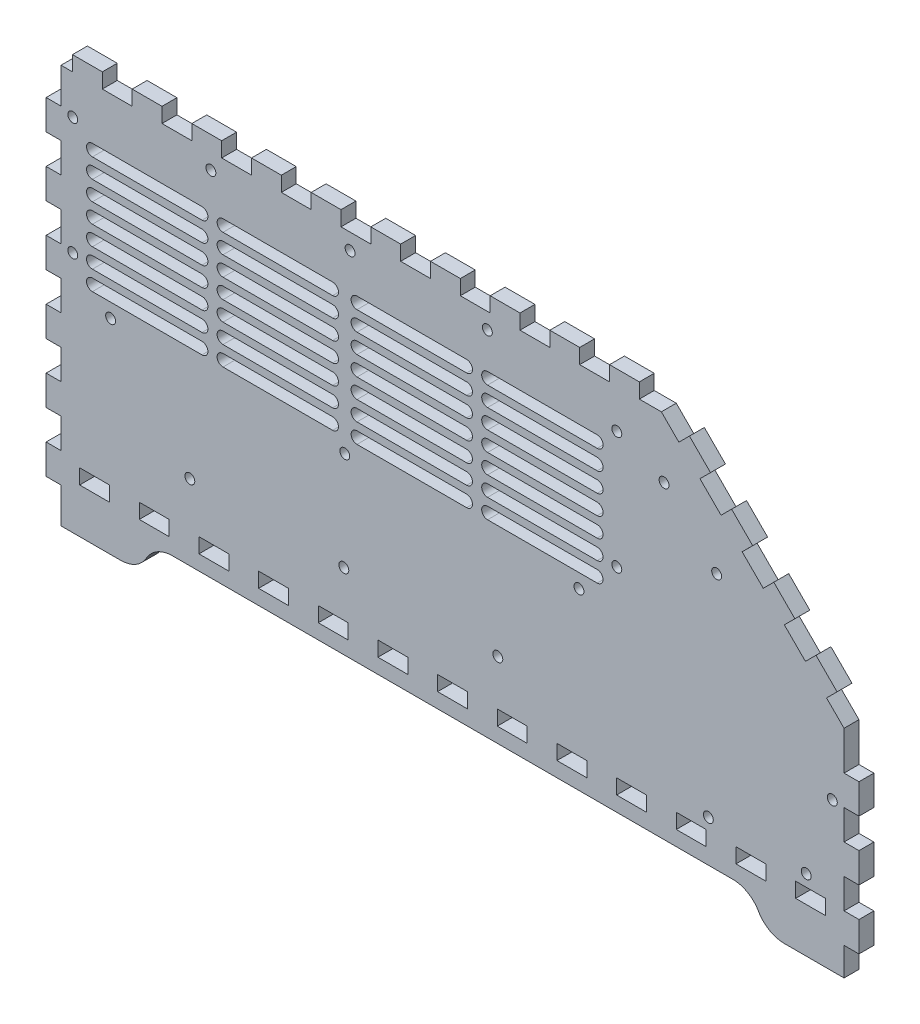
from build123d import *

# Parameters (mm, degrees)
BOSS_EXTRUDE1_DEPTH   = 5.715
CUT_EXTRUDE1_DEPTH    = 6.715
F_6_CLEARANCE_HOLE1_D = 3.7973


with BuildPart() as part:
    # Model → Boss-Extrude1 (new body)
    with BuildSketch(Plane.XY):
        Polygon((16.1148, 22.8575), (38.9749, 22.8575), (39.3485, 22.8575), (40.4689, 22.9567), (41.9322, 23.2475), (43.3447, 23.7271), (44.366, 24.2025), (44.6899, 24.3885), (44.8511, 24.4822), (45.3263, 24.7854), (45.9341, 25.2222), (46.5116, 25.6963), (47.056, 26.2062), (47.5657, 26.7505), (48.0399, 27.3279), (48.4766, 27.9356), (48.7796, 28.411), (48.8735, 28.5722), (48.9673, 28.7348), (49.2689, 29.2103), (49.7057, 29.818), (50.1798, 30.3954), (50.6899, 30.9397), (51.2339, 31.4496), (51.8114, 31.9236), (52.4192, 32.3605), (52.8948, 32.6622), (53.0571, 32.756), (53.3799, 32.9434), (54.4008, 33.4188), (55.8133, 33.8983), (57.2766, 34.1891), (58.3971, 34.287), (58.7721, 34.287), (273.458, 34.287), (273.831, 34.287), (274.952, 34.1891), (276.415, 33.8983), (277.828, 33.4188), (278.849, 32.9434), (279.172, 32.756), (279.334, 32.6636), (279.809, 32.3605), (280.417, 31.9236), (280.995, 31.4496), (281.539, 30.9397), (282.049, 30.3954), (282.523, 29.818), (282.96, 29.2103), (283.263, 28.7348), (283.356, 28.5722), (283.449, 28.411), (283.752, 27.9356), (284.189, 27.3279), (284.663, 26.7505), (285.172, 26.2062), (285.717, 25.6963), (286.294, 25.2222), (286.902, 24.7854), (287.377, 24.4822), (287.54, 24.3885), (287.862, 24.2025), (288.884, 23.7271), (290.296, 23.2475), (291.76, 22.9567), (292.88, 22.8575), (293.255, 22.8575), (316.115, 22.8575), (316.115, 33.6917), (321.83, 33.6917), (321.83, 45.1224), (316.115, 45.1224), (316.115, 56.552), (321.83, 56.552), (321.83, 67.9813), (316.115, 67.9813), (316.115, 79.412), (321.83, 79.412), (321.83, 90.8417), (316.115, 90.8417), (316.115, 101.677), (316.115, 105.718), (309.403, 112.43), (313.444, 116.47), (305.362, 124.553), (301.321, 120.512), (293.238, 128.595), (297.28, 132.635), (289.198, 140.717), (285.156, 136.677), (277.074, 144.759), (281.114, 148.801), (273.032, 156.881), (268.992, 152.841), (260.91, 160.923), (264.951, 164.963), (256.869, 173.046), (252.827, 169.005), (246.115, 175.718), (242.074, 175.718), (237.68, 175.718), (237.68, 181.433), (226.249, 181.433), (226.249, 175.718), (214.82, 175.718), (214.82, 181.433), (203.389, 181.433), (203.389, 175.718), (191.959, 175.718), (191.959, 181.433), (180.53, 181.433), (180.53, 175.718), (169.099, 175.718), (169.099, 181.433), (157.67, 181.433), (157.67, 175.718), (146.239, 175.718), (146.239, 181.433), (134.809, 181.433), (134.809, 175.718), (123.38, 175.718), (123.38, 181.433), (111.949, 181.433), (111.949, 175.718), (100.52, 175.718), (100.52, 181.433), (89.0887, 181.433), (89.0887, 175.718), (77.6594, 175.718), (77.6594, 181.433), (66.2298, 181.433), (66.2298, 175.718), (54.7991, 175.718), (54.7991, 181.433), (43.3698, 181.433), (43.3698, 175.718), (31.9388, 175.718), (31.9388, 181.433), (20.5093, 181.433), (20.5093, 175.718), (16.1148, 175.718), (16.1148, 162.153), (10.4001, 162.153), (10.4001, 150.723), (16.1148, 150.723), (16.1148, 139.292), (10.4001, 139.292), (10.4001, 127.863), (16.1148, 127.863), (16.1148, 116.433), (10.4001, 116.433), (10.4001, 105.003), (16.1148, 105.003), (16.1148, 93.5729), (10.4001, 93.5729), (10.4001, 82.1422), (16.1148, 82.1422), (16.1148, 70.7125), (10.4001, 70.7125), (10.4001, 59.2832), (16.1148, 59.2832), (16.1148, 47.8525), (10.4001, 47.8525), (10.4001, 36.4229), (16.1148, 36.4229), align=None)
        Polygon((28.9553, 40.0032), (23.2406, 40.0032), (23.2406, 45.7179), (34.67, 45.7179), (34.67, 40.0032), align=None, mode=Mode.SUBTRACT)
        Polygon((51.8156, 40.0032), (46.0996, 40.0032), (46.0996, 45.7179), (57.5303, 45.7179), (57.5303, 40.0032), align=None, mode=Mode.SUBTRACT)
        Polygon((74.6746, 40.0032), (68.9599, 40.0032), (68.9599, 45.7179), (80.3906, 45.7179), (80.3906, 40.0032), align=None, mode=Mode.SUBTRACT)
        Polygon((97.5349, 40.0032), (91.8199, 40.0032), (91.8199, 45.7179), (103.25, 45.7179), (103.25, 40.0032), align=None, mode=Mode.SUBTRACT)
        Polygon((120.395, 40.0032), (114.68, 40.0032), (114.68, 45.7179), (126.11, 45.7179), (126.11, 40.0032), align=None, mode=Mode.SUBTRACT)
        Polygon((143.255, 40.0032), (137.541, 40.0032), (137.541, 45.7179), (148.97, 45.7179), (148.97, 40.0032), align=None, mode=Mode.SUBTRACT)
        Polygon((166.116, 40.0032), (160.4, 40.0032), (160.4, 45.7179), (171.83, 45.7179), (171.83, 40.0032), align=None, mode=Mode.SUBTRACT)
        Polygon((188.975, 40.0032), (183.26, 40.0032), (183.26, 45.7179), (194.691, 45.7179), (194.691, 40.0032), align=None, mode=Mode.SUBTRACT)
        Polygon((211.835, 40.0032), (206.12, 40.0032), (206.12, 45.7179), (217.55, 45.7179), (217.55, 40.0032), align=None, mode=Mode.SUBTRACT)
        Polygon((234.695, 40.0032), (228.98, 40.0032), (228.98, 45.7179), (240.41, 45.7179), (240.41, 40.0032), align=None, mode=Mode.SUBTRACT)
        Polygon((257.555, 40.0032), (251.841, 40.0032), (251.841, 45.7179), (263.27, 45.7179), (263.27, 40.0032), align=None, mode=Mode.SUBTRACT)
        Polygon((280.416, 40.0032), (274.7, 40.0032), (274.7, 45.7179), (286.13, 45.7179), (286.13, 40.0032), align=None, mode=Mode.SUBTRACT)
        Polygon((303.275, 40.0032), (297.56, 40.0032), (297.56, 45.7179), (308.991, 45.7179), (308.991, 40.0032), align=None, mode=Mode.SUBTRACT)
    extrude(amount=BOSS_EXTRUDE1_DEPTH)

    # Sketch1 → Cut-Extrude1 (cut, through all)
    with BuildSketch(Plane(origin=(0, 0, 0), x_dir=(-1, 0, 0), z_dir=(0, 0, -1))):
        with BuildLine():
            Line((-221.535820417, 155.8109373), (-179.535820417, 155.8109373))
            ThreePointArc((-179.535820417, 155.8109373), (-177.285820417, 153.5609373), (-179.535820417, 151.3109373))
            Line((-179.535820417, 151.3109373), (-221.535820417, 151.3109373))
            ThreePointArc((-221.535820417, 151.3109373), (-223.785820417, 153.5609373), (-221.535820417, 155.8109373))
        make_face()
        with BuildLine():
            Line((-221.535820417, 143.8609373), (-179.535820417, 143.8609373))
            ThreePointArc((-179.535820417, 143.8609373), (-177.285820417, 146.1109373), (-179.535820417, 148.3609373))
            Line((-179.535820417, 148.3609373), (-221.535820417, 148.3609373))
            ThreePointArc((-221.535820417, 148.3609373), (-223.785820417, 146.1109373), (-221.535820417, 143.8609373))
        make_face()
        with BuildLine():
            Line((-221.535820417, 136.4109373), (-179.535820417, 136.4109373))
            ThreePointArc((-179.535820417, 136.4109373), (-177.285820417, 138.6609373), (-179.535820417, 140.9109373))
            Line((-179.535820417, 140.9109373), (-221.535820417, 140.9109373))
            ThreePointArc((-221.535820417, 140.9109373), (-223.785820417, 138.6609373), (-221.535820417, 136.4109373))
        make_face()
        with BuildLine():
            Line((-221.535820417, 128.9609373), (-179.535820417, 128.9609373))
            ThreePointArc((-179.535820417, 128.9609373), (-177.285820417, 131.2109373), (-179.535820417, 133.4609373))
            Line((-179.535820417, 133.4609373), (-221.535820417, 133.4609373))
            ThreePointArc((-221.535820417, 133.4609373), (-223.785820417, 131.2109373), (-221.535820417, 128.9609373))
        make_face()
        with BuildLine():
            Line((-221.535820417, 121.5109373), (-179.535820417, 121.5109373))
            ThreePointArc((-179.535820417, 121.5109373), (-177.285820417, 123.7609373), (-179.535820417, 126.0109373))
            Line((-179.535820417, 126.0109373), (-221.535820417, 126.0109373))
            ThreePointArc((-221.535820417, 126.0109373), (-223.785820417, 123.7609373), (-221.535820417, 121.5109373))
        make_face()
        with BuildLine():
            Line((-221.535820417, 114.0609373), (-179.535820417, 114.0609373))
            ThreePointArc((-179.535820417, 114.0609373), (-177.285820417, 116.3109373), (-179.535820417, 118.5609373))
            Line((-179.535820417, 118.5609373), (-221.535820417, 118.5609373))
            ThreePointArc((-221.535820417, 118.5609373), (-223.785820417, 116.3109373), (-221.535820417, 114.0609373))
        make_face()
        with BuildLine():
            Line((-221.535820417, 106.6109373), (-179.535820417, 106.6109373))
            ThreePointArc((-179.535820417, 106.6109373), (-177.285820417, 108.8609373), (-179.535820417, 111.1109373))
            Line((-179.535820417, 111.1109373), (-221.535820417, 111.1109373))
            ThreePointArc((-221.535820417, 111.1109373), (-223.785820417, 108.8609373), (-221.535820417, 106.6109373))
        make_face()
        with BuildLine():
            Line((-129.503720992, 111.1109373), (-171.503720992, 111.1109373))
            ThreePointArc((-171.503720992, 111.1109373), (-173.753720992, 108.8609373), (-171.503720992, 106.6109373))
            Line((-171.503720992, 106.6109373), (-129.503720992, 106.6109373))
            ThreePointArc((-129.503720992, 106.6109373), (-127.253720992, 108.8609373), (-129.503720992, 111.1109373))
        make_face()
        with BuildLine():
            Line((-129.503720992, 118.5609373), (-171.503720992, 118.5609373))
            ThreePointArc((-171.503720992, 118.5609373), (-173.753720992, 116.3109373), (-171.503720992, 114.0609373))
            Line((-171.503720992, 114.0609373), (-129.503720992, 114.0609373))
            ThreePointArc((-129.503720992, 114.0609373), (-127.253720992, 116.3109373), (-129.503720992, 118.5609373))
        make_face()
        with BuildLine():
            Line((-129.503720992, 126.0109373), (-171.503720992, 126.0109373))
            ThreePointArc((-171.503720992, 126.0109373), (-173.753720992, 123.7609373), (-171.503720992, 121.5109373))
            Line((-171.503720992, 121.5109373), (-129.503720992, 121.5109373))
            ThreePointArc((-129.503720992, 121.5109373), (-127.253720992, 123.7609373), (-129.503720992, 126.0109373))
        make_face()
        with BuildLine():
            Line((-129.503720992, 133.4609373), (-171.503720992, 133.4609373))
            ThreePointArc((-171.503720992, 133.4609373), (-173.753720992, 131.2109373), (-171.503720992, 128.9609373))
            Line((-171.503720992, 128.9609373), (-129.503720992, 128.9609373))
            ThreePointArc((-129.503720992, 128.9609373), (-127.253720992, 131.2109373), (-129.503720992, 133.4609373))
        make_face()
        with BuildLine():
            Line((-129.503720992, 140.9109373), (-171.503720992, 140.9109373))
            ThreePointArc((-171.503720992, 140.9109373), (-173.753720992, 138.6609373), (-171.503720992, 136.4109373))
            Line((-171.503720992, 136.4109373), (-129.503720992, 136.4109373))
            ThreePointArc((-129.503720992, 136.4109373), (-127.253720992, 138.6609373), (-129.503720992, 140.9109373))
        make_face()
        with BuildLine():
            Line((-129.503720992, 148.3609373), (-171.503720992, 148.3609373))
            ThreePointArc((-171.503720992, 148.3609373), (-173.753720992, 146.1109373), (-171.503720992, 143.8609373))
            Line((-171.503720992, 143.8609373), (-129.503720992, 143.8609373))
            ThreePointArc((-129.503720992, 143.8609373), (-127.253720992, 146.1109373), (-129.503720992, 148.3609373))
        make_face()
        with BuildLine():
            Line((-129.503720992, 155.8109373), (-171.503720992, 155.8109373))
            ThreePointArc((-171.503720992, 155.8109373), (-173.753720992, 153.5609373), (-171.503720992, 151.3109373))
            Line((-171.503720992, 151.3109373), (-129.503720992, 151.3109373))
            ThreePointArc((-129.503720992, 151.3109373), (-127.253720992, 153.5609373), (-129.503720992, 155.8109373))
        make_face()
        with BuildLine():
            Line((-28.134624406, 155.8109373), (-70.134624406, 155.8109373))
            ThreePointArc((-70.134624406, 155.8109373), (-72.384624406, 153.5609373), (-70.134624406, 151.3109373))
            Line((-70.134624406, 151.3109373), (-28.134624406, 151.3109373))
            ThreePointArc((-28.134624406, 151.3109373), (-25.884624406, 153.5609373), (-28.134624406, 155.8109373))
        make_face()
        with BuildLine():
            Line((-28.134624406, 148.3609373), (-70.134624406, 148.3609373))
            ThreePointArc((-70.134624406, 148.3609373), (-72.384624406, 146.1109373), (-70.134624406, 143.8609373))
            Line((-70.134624406, 143.8609373), (-28.134624406, 143.8609373))
            ThreePointArc((-28.134624406, 143.8609373), (-25.884624406, 146.1109373), (-28.134624406, 148.3609373))
        make_face()
        with BuildLine():
            Line((-28.134624406, 140.9109373), (-70.134624406, 140.9109373))
            ThreePointArc((-70.134624406, 140.9109373), (-72.384624406, 138.6609373), (-70.134624406, 136.4109373))
            Line((-70.134624406, 136.4109373), (-28.134624406, 136.4109373))
            ThreePointArc((-28.134624406, 136.4109373), (-25.884624406, 138.6609373), (-28.134624406, 140.9109373))
        make_face()
        with BuildLine():
            Line((-28.134624406, 133.4609373), (-70.134624406, 133.4609373))
            ThreePointArc((-70.134624406, 133.4609373), (-72.384624406, 131.2109373), (-70.134624406, 128.9609373))
            Line((-70.134624406, 128.9609373), (-28.134624406, 128.9609373))
            ThreePointArc((-28.134624406, 128.9609373), (-25.884624406, 131.2109373), (-28.134624406, 133.4609373))
        make_face()
        with BuildLine():
            Line((-28.134624406, 126.0109373), (-70.134624406, 126.0109373))
            ThreePointArc((-70.134624406, 126.0109373), (-72.384624406, 123.7609373), (-70.134624406, 121.5109373))
            Line((-70.134624406, 121.5109373), (-28.134624406, 121.5109373))
            ThreePointArc((-28.134624406, 121.5109373), (-25.884624406, 123.7609373), (-28.134624406, 126.0109373))
        make_face()
        with BuildLine():
            Line((-28.134624406, 118.5609373), (-70.134624406, 118.5609373))
            ThreePointArc((-70.134624406, 118.5609373), (-72.384624406, 116.3109373), (-70.134624406, 114.0609373))
            Line((-70.134624406, 114.0609373), (-28.134624406, 114.0609373))
            ThreePointArc((-28.134624406, 114.0609373), (-25.884624406, 116.3109373), (-28.134624406, 118.5609373))
        make_face()
        with BuildLine():
            Line((-28.134624406, 111.1109373), (-70.134624406, 111.1109373))
            ThreePointArc((-70.134624406, 111.1109373), (-72.384624406, 108.8609373), (-70.134624406, 106.6109373))
            Line((-70.134624406, 106.6109373), (-28.134624406, 106.6109373))
            ThreePointArc((-28.134624406, 106.6109373), (-25.884624406, 108.8609373), (-28.134624406, 111.1109373))
        make_face()
        with BuildLine():
            Line((-120.166723831, 111.1109373), (-78.166723831, 111.1109373))
            ThreePointArc((-78.166723831, 111.1109373), (-75.916723831, 108.8609373), (-78.166723831, 106.6109373))
            Line((-78.166723831, 106.6109373), (-120.166723831, 106.6109373))
            ThreePointArc((-120.166723831, 106.6109373), (-122.416723831, 108.8609373), (-120.166723831, 111.1109373))
        make_face()
        with BuildLine():
            Line((-120.166723831, 118.5609373), (-78.166723831, 118.5609373))
            ThreePointArc((-78.166723831, 118.5609373), (-75.916723831, 116.3109373), (-78.166723831, 114.0609373))
            Line((-78.166723831, 114.0609373), (-120.166723831, 114.0609373))
            ThreePointArc((-120.166723831, 114.0609373), (-122.416723831, 116.3109373), (-120.166723831, 118.5609373))
        make_face()
        with BuildLine():
            Line((-120.166723831, 126.0109373), (-78.166723831, 126.0109373))
            ThreePointArc((-78.166723831, 126.0109373), (-75.916723831, 123.7609373), (-78.166723831, 121.5109373))
            Line((-78.166723831, 121.5109373), (-120.166723831, 121.5109373))
            ThreePointArc((-120.166723831, 121.5109373), (-122.416723831, 123.7609373), (-120.166723831, 126.0109373))
        make_face()
        with BuildLine():
            Line((-120.166723831, 133.4609373), (-78.166723831, 133.4609373))
            ThreePointArc((-78.166723831, 133.4609373), (-75.916723831, 131.2109373), (-78.166723831, 128.9609373))
            Line((-78.166723831, 128.9609373), (-120.166723831, 128.9609373))
            ThreePointArc((-120.166723831, 128.9609373), (-122.416723831, 131.2109373), (-120.166723831, 133.4609373))
        make_face()
        with BuildLine():
            Line((-120.166723831, 140.9109373), (-78.166723831, 140.9109373))
            ThreePointArc((-78.166723831, 140.9109373), (-75.916723831, 138.6609373), (-78.166723831, 136.4109373))
            Line((-78.166723831, 136.4109373), (-120.166723831, 136.4109373))
            ThreePointArc((-120.166723831, 136.4109373), (-122.416723831, 138.6609373), (-120.166723831, 140.9109373))
        make_face()
        with BuildLine():
            Line((-120.166723831, 148.3609373), (-78.166723831, 148.3609373))
            ThreePointArc((-78.166723831, 148.3609373), (-75.916723831, 146.1109373), (-78.166723831, 143.8609373))
            Line((-78.166723831, 143.8609373), (-120.166723831, 143.8609373))
            ThreePointArc((-120.166723831, 143.8609373), (-122.416723831, 146.1109373), (-120.166723831, 148.3609373))
        make_face()
        with BuildLine():
            Line((-120.166723831, 155.8109373), (-78.166723831, 155.8109373))
            ThreePointArc((-78.166723831, 155.8109373), (-75.916723831, 153.5609373), (-78.166723831, 151.3109373))
            Line((-78.166723831, 151.3109373), (-120.166723831, 151.3109373))
            ThreePointArc((-120.166723831, 151.3109373), (-122.416723831, 153.5609373), (-120.166723831, 155.8109373))
        make_face()
    extrude(amount=-CUT_EXTRUDE1_DEPTH, mode=Mode.SUBTRACT)

    # #6 Clearance Hole1 (through all)
    with Locations(Plane(origin=(0, 0, 0), x_dir=(-1, 0, 0), z_dir=(0, 0, -1))):
        with Locations((-126.869, 169.5805), (-73.535666667, 169.5805), (-179.452333333, 169.5805), (-229.0515, 160.7182), (-229.0515, 115.7182), (-214.5515, 101.2182), (-183.46025, 63.2182), (-124.46025, 63.2182), (-124.83315, 101.2182), (-35.1148, 101.2182), (-20.6148, 115.7182), (-65.46025, 63.2182), (-20.6148, 160.7182), (-311.618, 79.7182), (-301.618, 50.2182), (-264.118, 50.2182), (-267.301887771, 132.610802012), (-247.149344507, 152.763345276)):
            Hole(F_6_CLEARANCE_HOLE1_D / 2)


solid = part.part
